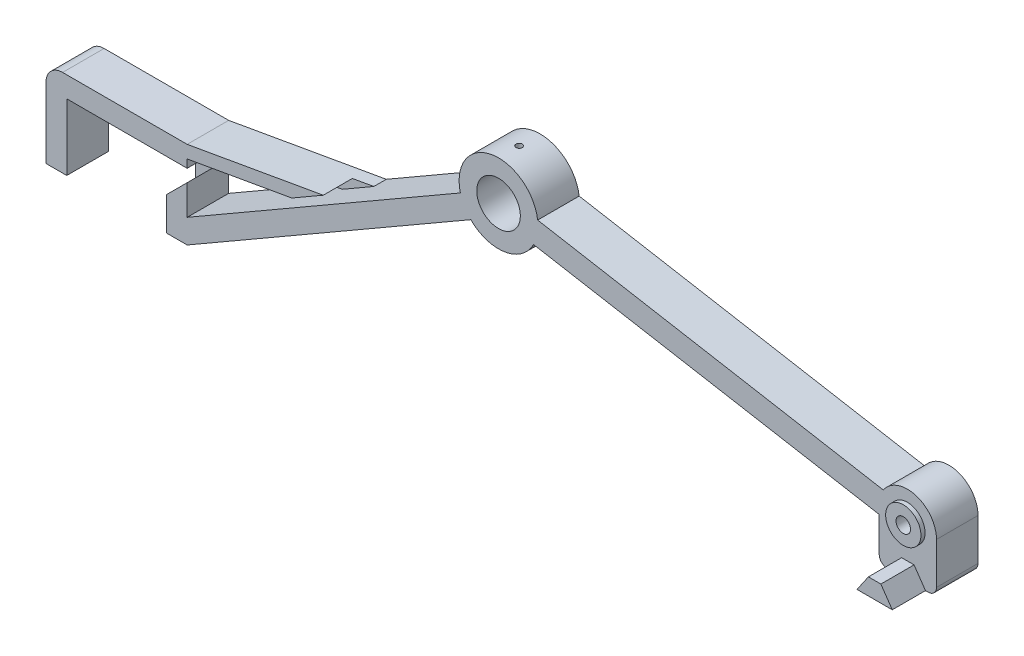
from build123d import *

# Parameters (mm, degrees)
SKICA1_R                 = 5.25
P_IDAT_VYSUNUT_M1_DEPTH  = 5
ZAOBLIT1_R               = 4
P_IDAT_VYSUNUT_M3_DEPTH  = 5
SKICA5_R                 = 4.25
SKICA5_R_2               = 1.75
P_IDAT_VYSUNUT_M4_DEPTH  = 1
SKICA8_R                 = 1.05
ODEBRAT_VYSUNUT_M3_DEPTH = 6
ODEBRAT_VYSUNUT_M4_DEPTH = 7
SKICA2_R                 = 1.75
ODEBRAT_VYSUNUT_M5_DEPTH = 10
SKICA10_R                = 3.5
ODEBRAT_VYSUNUT_M6_DEPTH = 3
ODEBRAT_START            = 50
SKICA11_R                = 0.75
ODEBRAT_VYSUNUT_M7_DEPTH = 10
P_IDAT_VYSUNUT_M5_DEPTH  = 10
P_IDAT_VYSUNUT_M6_DEPTH  = 8
ZAOBLIT2_R               = 2
ODEBRAT_VYSUNUT_M8_DEPTH = 7


with BuildPart() as part:
    # Skica1 → Přidat vysunutím1 (new body, symmetric)
    with BuildSketch(Plane.XY):
        with BuildLine():
            Line((0, 0), (0, 16))
            Line((0, 16), (24, 16))
            Line((24, 16), (24, 0))
            Line((24, 0), (29, 0))
            Line((29, 0), (97.312746067, 39.440382331))
            ThreePointArc((97.312746067, 39.440382331), (105.473420704, 36.802978572), (112.433277726, 41.81425579))
            Line((112.433277726, 41.81425579), (195.687578405, 27.134276321))
            ThreePointArc((195.687578405, 27.134276321), (209.374429572, 27.607666525), (196.674905514, 32.733686604))
            Line((196.674905514, 32.733686604), (113.420604835, 47.413666074))
            ThreePointArc((113.420604835, 47.413666074), (102.174688824, 55.511016714), (94.812746067, 43.77050935))
            Line((94.812746067, 43.77050935), (29, 5.773502692))
            Line((29, 5.773502692), (29, 21))
            Line((29, 21), (-5, 21))
            Line((-5, 21), (-5, 0))
            Line((-5, 0), (0, 0))
        make_face()
        with Locations((104, 46.188021535)):
            Circle(SKICA1_R, mode=Mode.SUBTRACT)
    extrude(amount=P_IDAT_VYSUNUT_M1_DEPTH, both=True)

    # Zaoblit1
    zaoblit1_edges = [part.edges().sort_by_distance(p)[0] for p in [
        (-5, 21, 0),
    ]]
    fillet(zaoblit1_edges, radius=ZAOBLIT1_R)

    # Skica4 → Přidat vysunutím3 (add, symmetric)
    with BuildSketch(Plane.XY):
        Polygon((29, 21), (66.969109888, 27.694978507), (59.37284323, 23.309271907), (29, 17.953720164), align=None)
    extrude(amount=P_IDAT_VYSUNUT_M3_DEPTH, both=True)

    # Skica5 → Přidat vysunutím4 (add)
    with BuildSketch(Plane.XY.offset(5)):
        with Locations((202.480775301, 28.823203768)):
            Circle(SKICA5_R)
        with Locations((202.480775301, 28.823203768)):
            Circle(SKICA5_R_2, mode=Mode.SUBTRACT)
    extrude(amount=P_IDAT_VYSUNUT_M4_DEPTH)

    # Skica8 → Odebrat vysunutím3 (cut)
    with BuildSketch(Plane.XZ):
        with Locations((-1.5, 0)):
            Circle(SKICA8_R)
        with Locations((25.5, 0)):
            Circle(SKICA8_R)
    extrude(amount=-ODEBRAT_VYSUNUT_M3_DEPTH, mode=Mode.SUBTRACT)

    # Skica9 → Odebrat vysunutím4 (cut)
    with BuildSketch(Plane.XY.offset(5)):
        Polygon((24, 16), (29, 16), (29, 13), (24, 8), align=None)
    extrude(amount=-ODEBRAT_VYSUNUT_M4_DEPTH, mode=Mode.SUBTRACT)

    # Skica2 → Odebrat vysunutím5 (cut)
    with BuildSketch(Plane.XY.offset(5)):
        with Locations((202.480775301, 28.823203768)):
            Circle(SKICA2_R)
    extrude(amount=-ODEBRAT_VYSUNUT_M5_DEPTH, mode=Mode.SUBTRACT)

    # Skica10 → Odebrat vysunutím6 (cut)
    with BuildSketch(Plane(origin=(0, 0, -5), x_dir=(-1, 0, 0), z_dir=(0, 0, -1))):
        with Locations((-202.480775301, 28.823203768)):
            Circle(SKICA10_R)
    extrude(amount=-ODEBRAT_VYSUNUT_M6_DEPTH, mode=Mode.SUBTRACT)

    # Skica11 → Odebrat vysunutím7 (cut)
    with BuildSketch(Plane(origin=(0, 0, 0), x_dir=(1, 0, 0), z_dir=(0, 1, 0)).offset(ODEBRAT_START)):
        with Locations((103.960302418, 0)):
            Circle(SKICA11_R)
    extrude(amount=ODEBRAT_VYSUNUT_M7_DEPTH, mode=Mode.SUBTRACT)

    # Skica12 → Přidat vysunutím5 (add)
    with BuildSketch(Plane.XY.offset(5)):
        with BuildLine():
            Line((195.687578405, 27.134276321), (195.687578405, 16.823203768))
            Line((195.687578405, 16.823203768), (209.480775301, 16.823203768))
            Line((209.480775301, 16.823203768), (209.480775301, 28.823203768))
            ThreePointArc((209.480775301, 28.823203768), (203.331546047, 21.875096894), (195.687578405, 27.134276321))
        make_face()
    extrude(amount=-P_IDAT_VYSUNUT_M5_DEPTH)

    # Skica13 → Přidat vysunutím6 (add)
    with BuildSketch(Plane.XY.offset(5)):
        Polygon((201.084176853, 20.823203768), (204.084176853, 20.823203768), (206.834176853, 16.823203768), (198.334176853, 16.823203768), align=None)
    extrude(amount=P_IDAT_VYSUNUT_M6_DEPTH)

    # Zaoblit2
    zaoblit2_edges = [part.edges().sort_by_distance(p)[0] for p in [
        (209.480775301, 16.823203768, 0),
        (195.687578405, 16.823203768, 0),
    ]]
    fillet(zaoblit2_edges, radius=ZAOBLIT2_R)

    # Skica14 → Odebrat vysunutím8 (cut)
    with BuildSketch(Plane.XY.offset(5)):
        Polygon((59.37284323, 23.309271907), (66.969109888, 27.694978507), (61.786216453, 26.781094556), (54.189949795, 22.395387956), align=None)
    extrude(amount=-ODEBRAT_VYSUNUT_M8_DEPTH, mode=Mode.SUBTRACT)


solid = part.part
